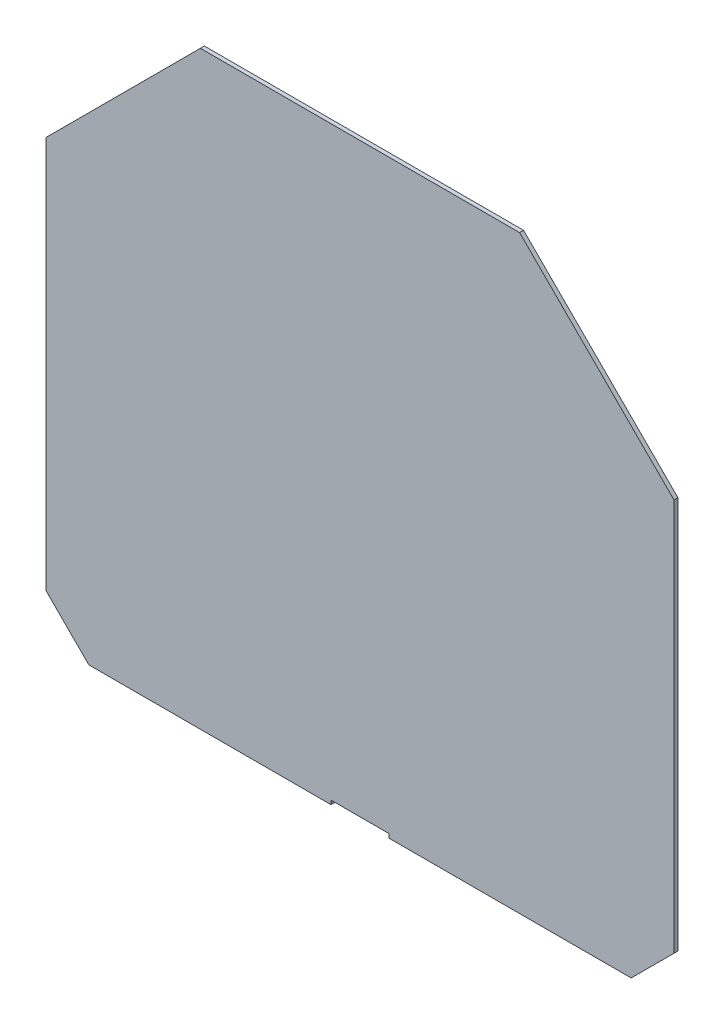
from build123d import *

# Parameters (mm, degrees)
BOSS_EXTRUDE1_DEPTH = 3


with BuildPart() as part:
    # Sketch2 → Boss-Extrude1 (new body)
    with BuildSketch(Plane.XY):
        Polygon((-22, -68.000002576), (22, -68.000002576), (22, -71.000002576), (205.356381254, -71.000002576), (237.804838801, -38.551545028), (237.804838801, 258.722127635), (120.878213038, 375.648753399), (-120.878213038, 375.648753399), (-237.804838801, 258.722127635), (-237.804838801, -38.551545028), (-205.356381254, -71.000002576), (-22, -71.000002576), align=None)
    extrude(amount=BOSS_EXTRUDE1_DEPTH)


solid = part.part
